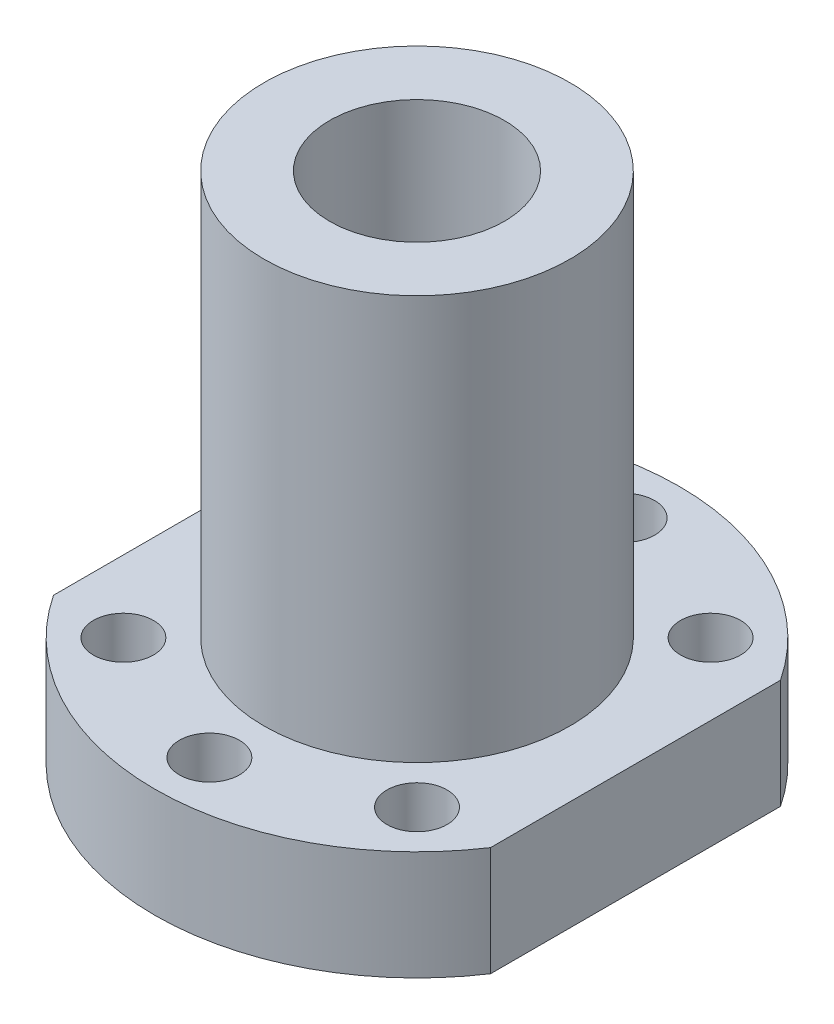
from build123d import *

# Parameters (mm, degrees)
SKETCH_1_R          = 2.75
SKETCH_1_R_2        = 14
EXTRUDE_1_DEPTH     = 10
SKETCH_1_3_R        = 14
SKETCH_1_3_R_2      = 8
EXTRUDE_2_DEPTH     = 47
SKETCH_2_R          = 3
CUT_EXTRUDE_1_DEPTH = 20


with BuildPart() as part:
    # 草图1 → 凸台-拉伸1 (new body)
    with BuildSketch(Plane(origin=(0, 0, 0), x_dir=(1, 0, 0), z_dir=(0, 1, 0))):
        with BuildLine():
            ThreePointArc((20, 13.266499161), (0, 24), (-20, 13.266499161))
            Line((-20, 13.266499161), (-20, -13.266499161))
            ThreePointArc((-20, -13.266499161), (0, -24), (20, -13.266499161))
            Line((20, -13.266499161), (20, 13.266499161))
        make_face()
        with Locations((-13.435028843, -13.435028843)):
            Circle(SKETCH_1_R, mode=Mode.SUBTRACT)
        with Locations((0, -19)):
            Circle(SKETCH_1_R, mode=Mode.SUBTRACT)
        with Locations((13.435028843, -13.435028843)):
            Circle(SKETCH_1_R, mode=Mode.SUBTRACT)
        Circle(SKETCH_1_R_2, mode=Mode.SUBTRACT)
        with Locations((-13.435028843, 13.435028843)):
            Circle(SKETCH_1_R, mode=Mode.SUBTRACT)
        with Locations((0, 19)):
            Circle(SKETCH_1_R, mode=Mode.SUBTRACT)
        with Locations((13.435028843, 13.435028843)):
            Circle(SKETCH_1_R, mode=Mode.SUBTRACT)
    extrude(amount=EXTRUDE_1_DEPTH)

    # 草图1<3> → 凸台-拉伸2 (add)
    with BuildSketch(Plane(origin=(0, 0, 0), x_dir=(1, 0, 0), z_dir=(0, 1, 0))):
        Circle(SKETCH_1_3_R)
        Circle(SKETCH_1_3_R_2, mode=Mode.SUBTRACT)
    extrude(amount=EXTRUDE_2_DEPTH)

    # 草图2 → 切除-拉伸1 (cut)
    with BuildSketch(Plane.ZY.offset(20)):
        with Locations((0, 5)):
            Circle(SKETCH_2_R)
    extrude(amount=-CUT_EXTRUDE_1_DEPTH, mode=Mode.SUBTRACT)


solid = part.part
